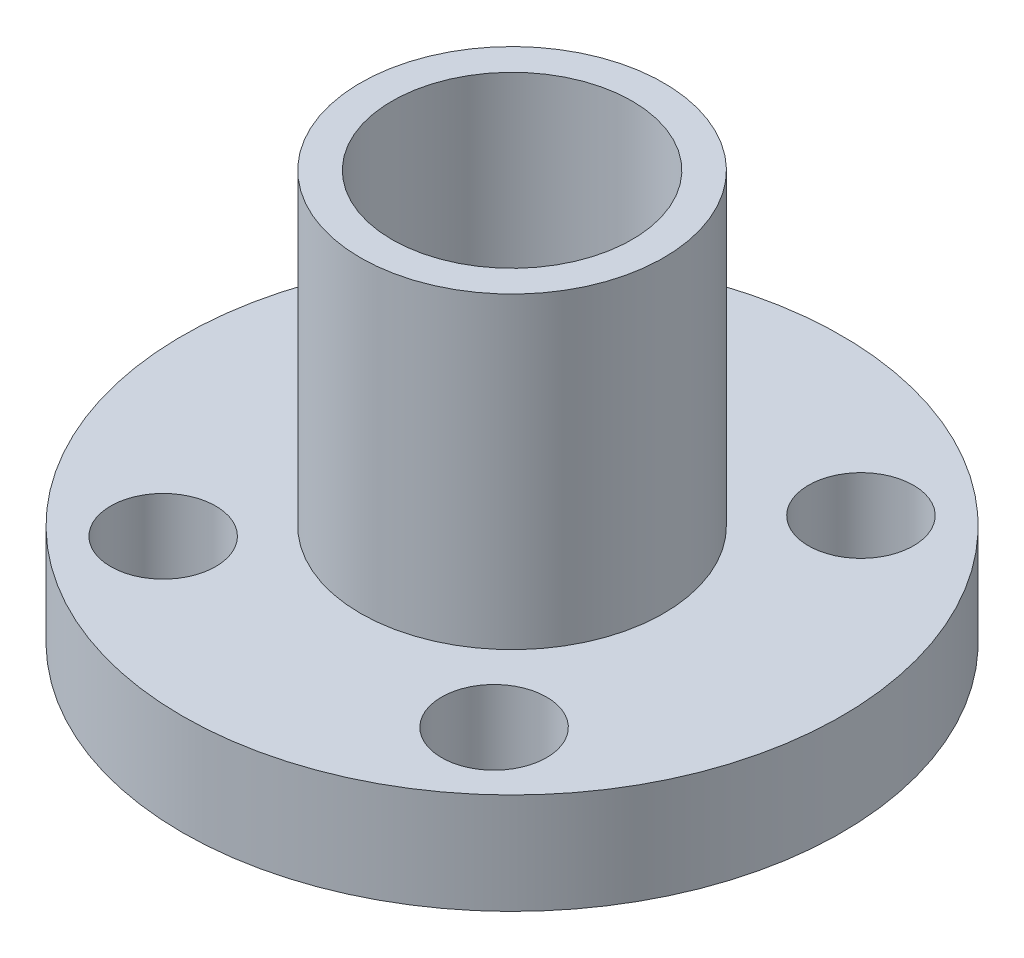
from build123d import *

# Parameters (mm, degrees)
CROQUIS2_R              = 10.98
CROQUIS2_R_2            = 1.75
SALIENTE_EXTRUIR1_DEPTH = 3.36
CROQUIS3_R              = 5.05
SALIENTE_EXTRUIR2_DEPTH = 10.26
CROQUIS4_R              = 5.05
SALIENTE_EXTRUIR3_DEPTH = 1.38
CROQUIS5_R              = 4
CORTAR_EXTRUIR1_DEPTH   = 16


with BuildPart() as part:
    # Croquis2 → Saliente-Extruir1 (new body)
    with BuildSketch(Plane(origin=(0, 0, 0), x_dir=(1, 0, 0), z_dir=(0, 1, 0))):
        Circle(CROQUIS2_R)
        with Locations((-5.512093558, 6.111442105)):
            Circle(CROQUIS2_R_2, mode=Mode.SUBTRACT)
        with Locations((-5.512093558, -6.111442105)):
            Circle(CROQUIS2_R_2, mode=Mode.SUBTRACT)
        with Locations((5.512093558, -6.111442105)):
            Circle(CROQUIS2_R_2, mode=Mode.SUBTRACT)
        with Locations((5.512093558, 6.111442105)):
            Circle(CROQUIS2_R_2, mode=Mode.SUBTRACT)
    extrude(amount=SALIENTE_EXTRUIR1_DEPTH)

    # Croquis3 → Saliente-Extruir2 (add)
    with BuildSketch(Plane(origin=(0, 3.36, 0), x_dir=(1, 0, 0), z_dir=(0, 1, 0))):
        Circle(CROQUIS3_R)
    extrude(amount=SALIENTE_EXTRUIR2_DEPTH)

    # Croquis4 → Saliente-Extruir3 (add)
    with BuildSketch(Plane.XZ):
        Circle(CROQUIS4_R)
    extrude(amount=SALIENTE_EXTRUIR3_DEPTH)

    # Croquis5 → Cortar-Extruir1 (cut, through all)
    with BuildSketch(Plane(origin=(0, 13.62, 0), x_dir=(1, 0, 0), z_dir=(0, 1, 0))):
        Circle(CROQUIS5_R)
    extrude(amount=-CORTAR_EXTRUIR1_DEPTH, mode=Mode.SUBTRACT)


solid = part.part
